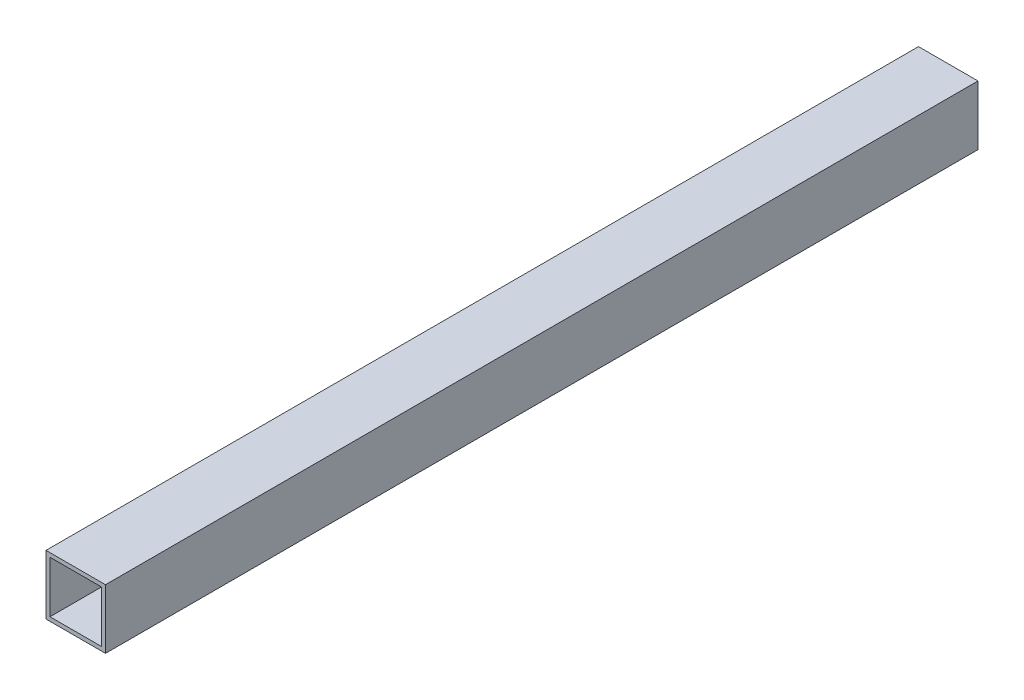
from build123d import *

# Parameters (mm, degrees)
ESBO_O1_W                = 30
ESBO_O1_H                = 30
RESSALTO_EXTRUS_O1_DEPTH = 440
CASCA1_T                 = -2


with BuildPart() as part:
    # Esboço1 → Ressalto-extrusão1 (new body)
    with BuildSketch(Plane.XY):
        with Locations((10.655165912, 87.212171493)):
            Rectangle(ESBO_O1_W, ESBO_O1_H)
    extrude(amount=RESSALTO_EXTRUS_O1_DEPTH)

    # Casca1
    casca1_openings = [part.faces().sort_by_distance(p)[0] for p in [
        (10.655165912, 87.212171493, 440),
        (10.655165912, 87.212171493, 0),
    ]]
    offset(amount=CASCA1_T, openings=casca1_openings, kind=Kind.INTERSECTION)


solid = part.part
